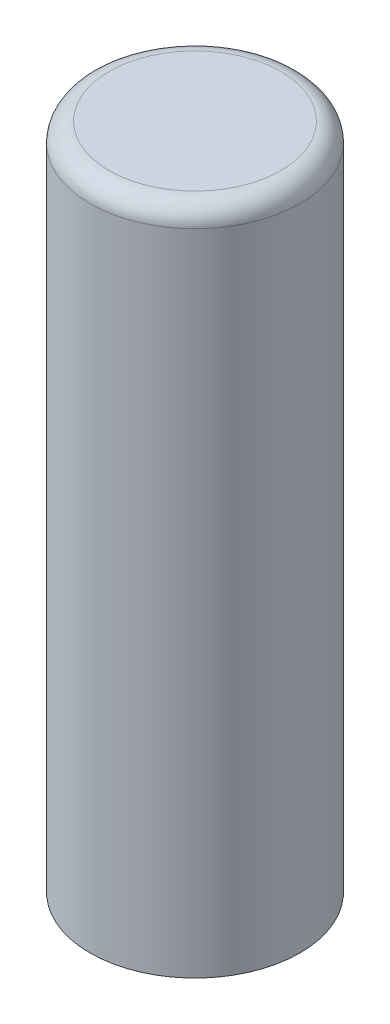
from build123d import *

# Parameters (mm, degrees)
SKETCH1_R           = 3.4925
BOSS_EXTRUDE1_DEPTH = 22.225
FILLET1_R           = 0.635
SKETCH2_R           = 1.778
CUT_EXTRUDE1_DEPTH  = 8.255


with BuildPart() as part:
    # Sketch1 → Boss-Extrude1 (new body)
    with BuildSketch(Plane(origin=(0, 0, 0), x_dir=(1, 0, 0), z_dir=(0, 1, 0))):
        Circle(SKETCH1_R)
    extrude(amount=BOSS_EXTRUDE1_DEPTH)

    # Fillet1
    fillet1_edges = [part.edges().sort_by_distance(p)[0] for p in [
        (-3.4925, 22.225, 0),
    ]]
    fillet(fillet1_edges, radius=FILLET1_R)

    # Sketch2 → Cut-Extrude1 (cut)
    with BuildSketch(Plane.XZ):
        Circle(SKETCH2_R)
    extrude(amount=-CUT_EXTRUDE1_DEPTH, mode=Mode.SUBTRACT)


solid = part.part
